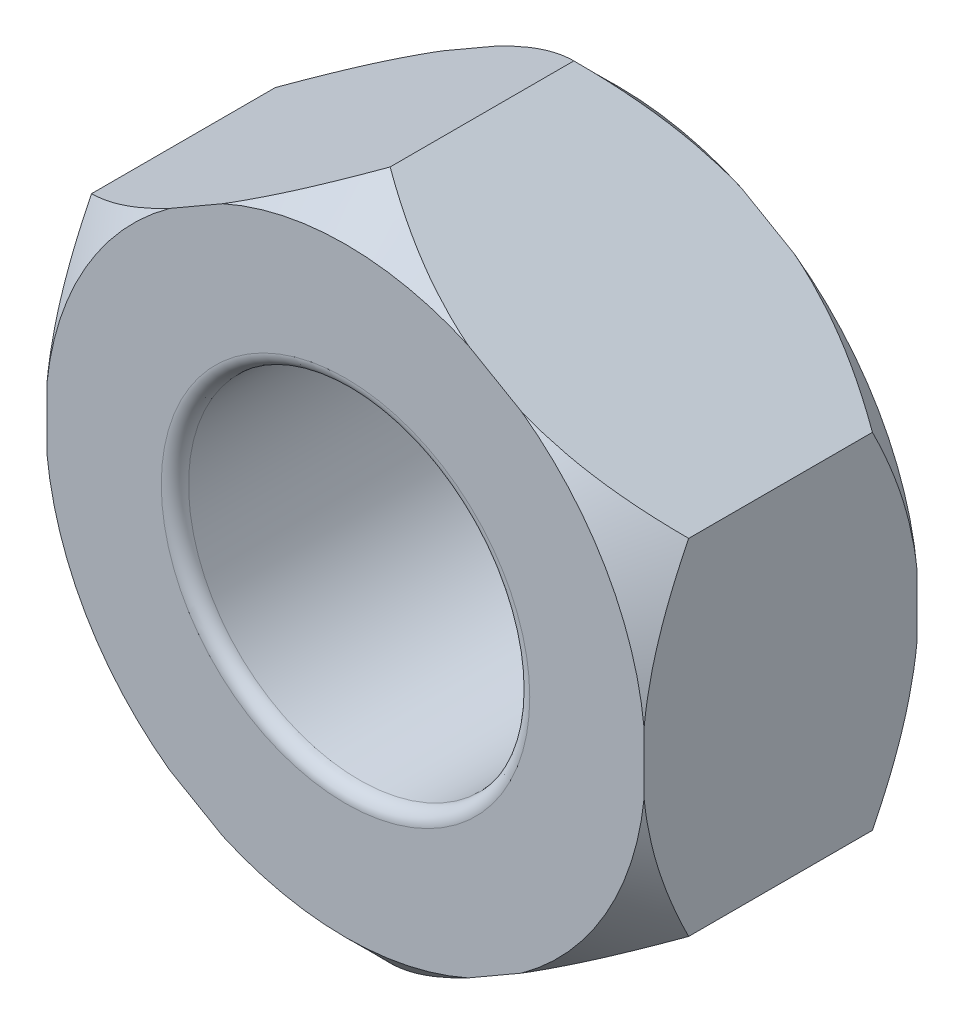
from build123d import *

# Parameters (mm, degrees)
EXTRUDE_1_DEPTH     = 3.2
SKETCH_2_R          = 2
CUT_EXTRUDE_1_DEPTH = 3.2
FILLET_1_R          = 0.16


with BuildPart() as part:
    # 草图1 → 凸台-拉伸1 (new body)
    with BuildSketch(Plane.XY):
        Polygon((0, 4.041451884), (-3.5, 2.020725942), (-3.5, -2.020725942), (0, -4.041451884), (3.5, -2.020725942), (3.5, 2.020725942), align=None)
    extrude(amount=EXTRUDE_1_DEPTH)

    # 草图2 → 切除-拉伸1 (cut)
    with BuildSketch(Plane(origin=(0, 0, 0), x_dir=(-1, 0, 0), z_dir=(0, 0, -1))):
        Circle(SKETCH_2_R)
    extrude(amount=-CUT_EXTRUDE_1_DEPTH, mode=Mode.SUBTRACT)

    # 草图4 → 切除-旋转1 (revolve, cut)
    with BuildSketch(Plane(origin=(0, 0, 0), x_dir=(0, 0, -1), z_dir=(1, 0, 0))):
        Polygon((-2.677, 4.041451884), (-3.2, 3.518451884), (-3.2, 4.041451884), align=None)
        Polygon((0, 4.041451884), (-0.523, 4.041451884), (0, 3.518451884), align=None)
    revolve(axis=Axis((0, 0, 0), (0, 0, 1)), mode=Mode.SUBTRACT)

    # 圆角1
    fillet_1_edges = [part.edges().sort_by_distance(p)[0] for p in [
        (2, 0, 3.2),
        (2, 0, 0),
    ]]
    fillet(fillet_1_edges, radius=FILLET_1_R)


solid = part.part
